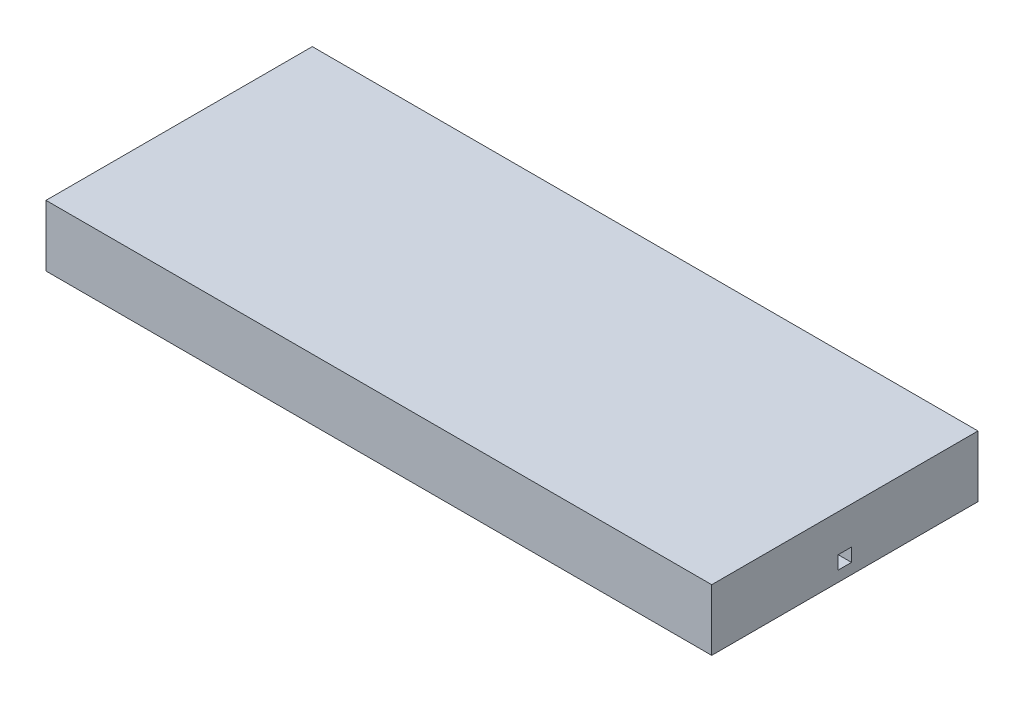
from build123d import *

# Parameters (mm, degrees)
SKETCH1_W           = 25
SKETCH1_H           = 10
BOSS_EXTRUDE1_DEPTH = 2.3
SKETCH2_W           = 0.85
SKETCH2_H           = 1.55
CUT_EXTRUDE1_DEPTH  = 0.4
CUT_EXTRUDE2_REACH  = 27
SKETCH3_W           = 0.5
SKETCH3_H           = 0.5
SKETCH7_W           = 1.25
SKETCH7_H           = 2
CUT_EXTRUDE4_DEPTH  = 0.4


with BuildPart() as part:
    # Sketch1 → Boss-Extrude1 (new body)
    with BuildSketch(Plane(origin=(0, 0, 0), x_dir=(1, 0, 0), z_dir=(0, 1, 0))):
        with Locations((12.5, 5)):
            Rectangle(SKETCH1_W, SKETCH1_H)
    extrude(amount=BOSS_EXTRUDE1_DEPTH)

    # Sketch2 → Cut-Extrude1 (cut)
    with BuildSketch(Plane.XZ):
        with Locations((8.2, -5)):
            Rectangle(SKETCH2_W, SKETCH2_H)
    extrude(amount=-CUT_EXTRUDE1_DEPTH, mode=Mode.SUBTRACT)

    # Sketch3 → Cut-Extrude2 (cut, up to next)
    with BuildSketch(Plane.ZY, mode=Mode.PRIVATE) as cut_extrude2_sk1:
        with Locations((-5, 0.65)):
            Rectangle(SKETCH3_W, SKETCH3_H)
    cut_extrude2_tool1 = extrude(cut_extrude2_sk1.sketch, amount=-CUT_EXTRUDE2_REACH, mode=Mode.PRIVATE) & part.part
    add(cut_extrude2_tool1.solids().sort_by_distance((0, 0.65, -5))[0], mode=Mode.SUBTRACT)

    # Sketch7 → Cut-Extrude4 (cut)
    with BuildSketch(Plane.XZ):
        with Locations((5, -5)):
            Rectangle(SKETCH7_W, SKETCH7_H)
        with Locations((11.4, -5)):
            Rectangle(SKETCH7_W, SKETCH7_H)
    extrude(amount=-CUT_EXTRUDE4_DEPTH, mode=Mode.SUBTRACT)


solid = part.part
